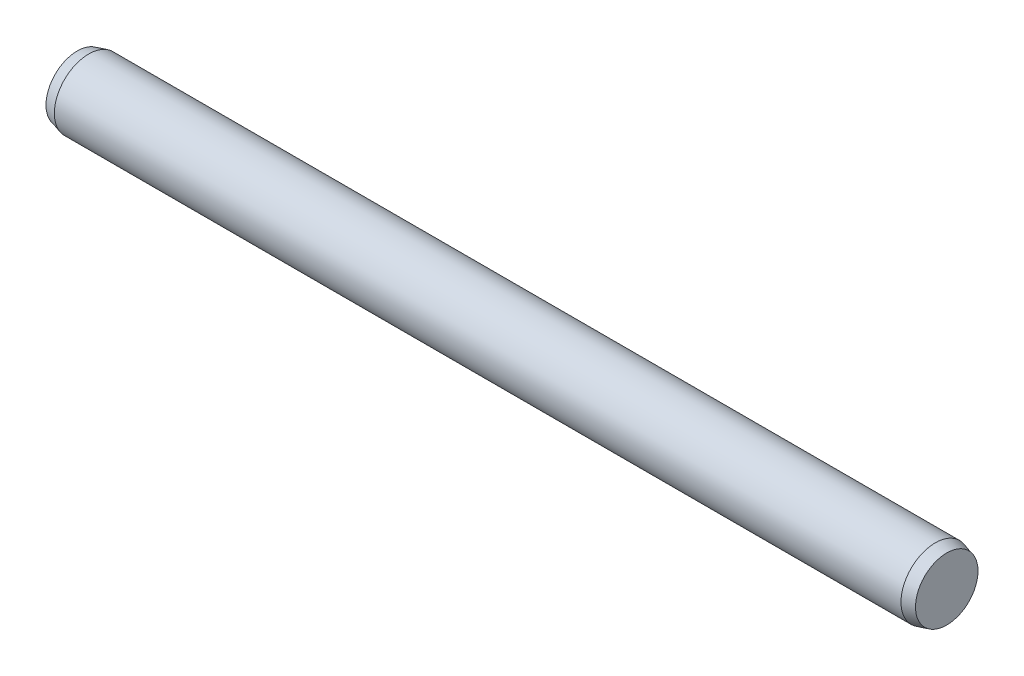
from build123d import *

# Parameters (mm, degrees)
SKETCH2_R           = 1.5
EXTRUDE1_DEPTH      = 18.5
EXTRUDE1_DEPTH_BACK = 18.5
SKETCH3_R           = 1.5
EXTRUDE2_DEPTH      = 0.5
EXTRUDE2_TAPER      = 15
SKETCH4_R           = 1.5
EXTRUDE3_DEPTH      = 0.5
EXTRUDE3_TAPER      = 15


with BuildPart() as part:
    # Sketch2 → Extrude1 (new body, two sides)
    with BuildSketch(Plane(origin=(0, 0, 0), x_dir=(0, 0, -1), z_dir=(1, 0, 0))) as extrude1_sk:
        Circle(SKETCH2_R)
    extrude(amount=EXTRUDE1_DEPTH)
    extrude(extrude1_sk.sketch, amount=-EXTRUDE1_DEPTH_BACK)

    # Sketch3 → Extrude2 (add)
    with BuildSketch(Plane(origin=(18.5, 0, 0), x_dir=(0, 0, -1), z_dir=(1, 0, 0))):
        Circle(SKETCH3_R)
    extrude(amount=EXTRUDE2_DEPTH, taper=EXTRUDE2_TAPER)

    # Sketch4 → Extrude3 (add)
    with BuildSketch(Plane.ZY.offset(18.5)):
        Circle(SKETCH4_R)
    extrude(amount=EXTRUDE3_DEPTH, taper=EXTRUDE3_TAPER)


solid = part.part
